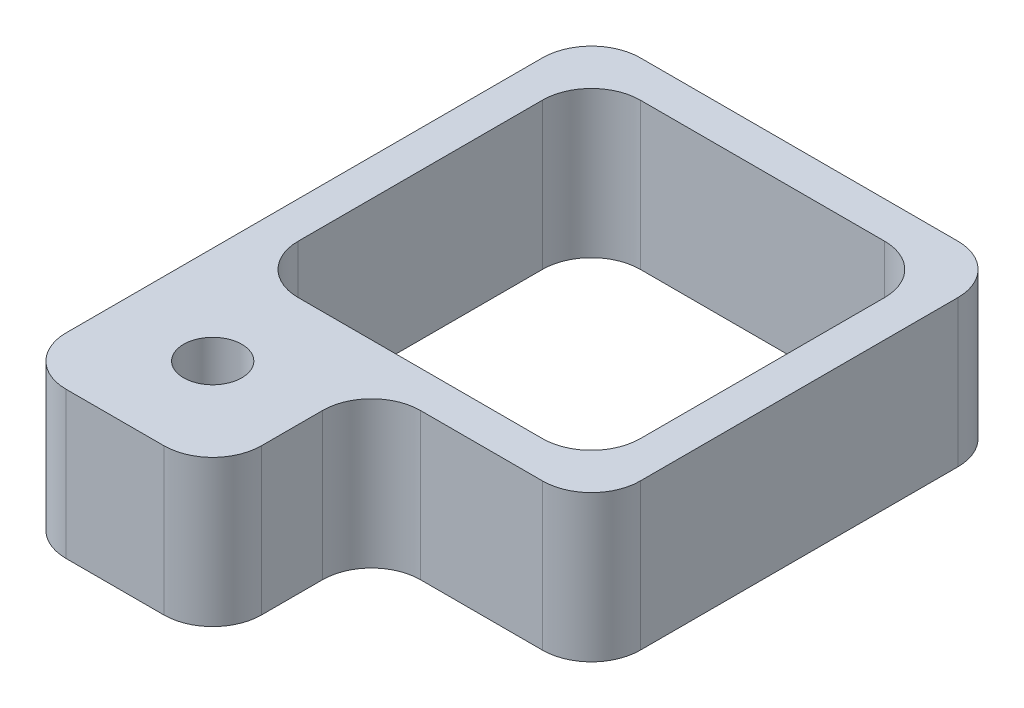
from build123d import *

# Parameters (mm, degrees)
SKETCH1_W             = 8.5
SKETCH1_H             = 8.5
EXTRUDE1_DEPTH        = 3
SKETCH3_W             = 4
SKETCH3_H             = 3
EXTRUDE3_DEPTH        = 3.25
SKETCH2_W             = 7
SKETCH2_H             = 7
EXTRUDE2_DEPTH        = 4
F_0_80_TAPPED_HOLE1_D = 1.19126
SKETCH11_W            = 2
SKETCH11_H            = 1
EXTRUDE5_DEPTH        = 1.5
FILLET1_R             = 1


with BuildPart() as part:
    # Sketch1 → Extrude1 (new body)
    with BuildSketch(Plane(origin=(0, 0, 0), x_dir=(1, 0, 0), z_dir=(0, 1, 0))):
        Rectangle(SKETCH1_W, SKETCH1_H)
    extrude(amount=EXTRUDE1_DEPTH)

    # Sketch3 → Extrude3 (add)
    with BuildSketch(Plane.XY.offset(4.25)):
        with Locations((-2.25, 1.5)):
            Rectangle(SKETCH3_W, SKETCH3_H)
    extrude(amount=EXTRUDE3_DEPTH)

    # Sketch2 → Extrude2 (cut, through all)
    with BuildSketch(Plane(origin=(0, 3, 0), x_dir=(1, 0, 0), z_dir=(0, 1, 0))):
        Rectangle(SKETCH2_W, SKETCH2_H)
    extrude(amount=-EXTRUDE2_DEPTH, mode=Mode.SUBTRACT)

    # #0-80 Tapped Hole1 (through all)
    with Locations(Plane(origin=(-2.25, 3, 5.5), x_dir=(0, 0, 1), z_dir=(0, 1, 0))):
        with Locations((0, 0)):
            Hole(F_0_80_TAPPED_HOLE1_D / 2)

    # Sketch11 → Extrude5 (add)
    with BuildSketch(Plane(origin=(0, 0, -4.25), x_dir=(-1, 0, 0), z_dir=(0, 0, -1))):
        with Locations((-0.42960296, 0.5)):
            Rectangle(SKETCH11_W, SKETCH11_H)
    extrude(amount=EXTRUDE5_DEPTH)

    # Fillet1
    fillet1_edges = [part.edges().sort_by_distance(p)[0] for p in [
        (3.5, 1.5, -3.5),
        (-3.5, 1.5, -3.5),
        (-3.5, 1.5, 3.5),
        (3.5, 1.5, 3.5),
        (-4.25, 1.5, 7.5),
        (-0.25, 1.5, 7.5),
        (-0.25, 1.5, 4.25),
        (4.25, 1.5, 4.25),
        (4.25, 1.5, -4.25),
        (-4.25, 1.5, -4.25),
    ]]
    fillet(fillet1_edges, radius=FILLET1_R)


solid = part.part
